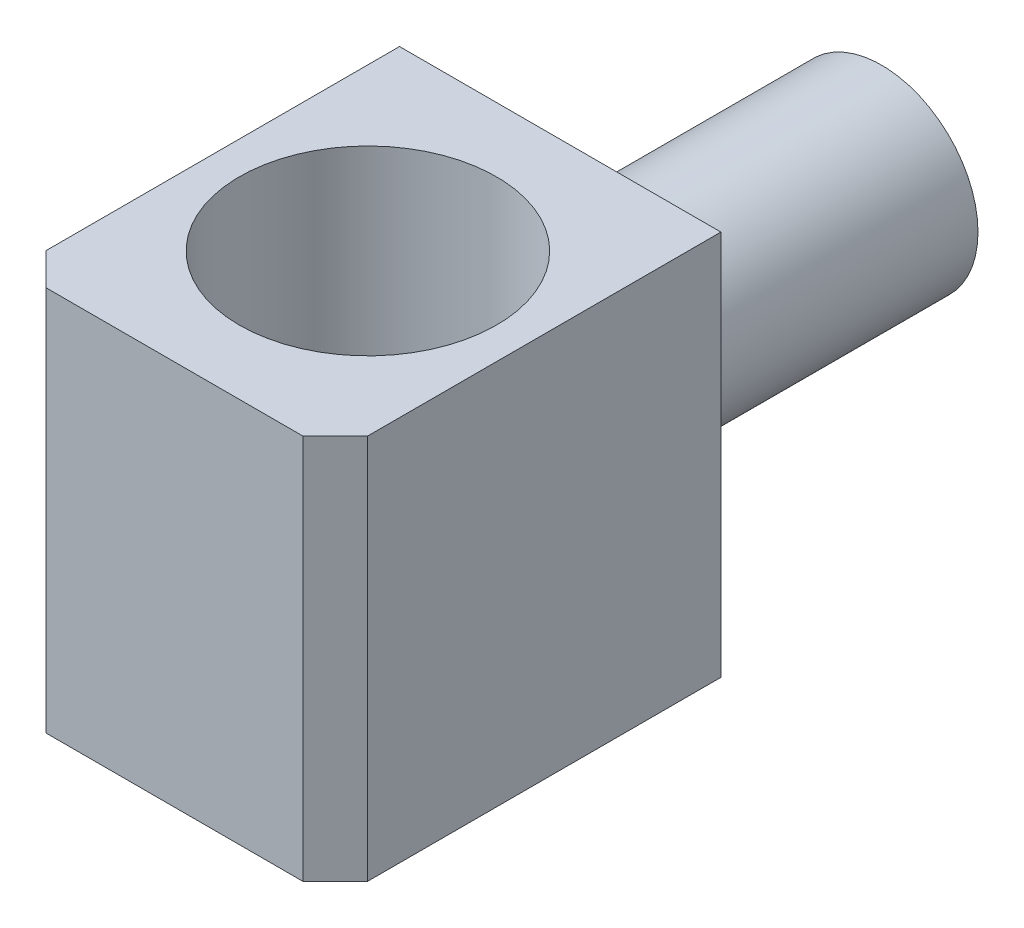
from build123d import *

# Parameters (mm, degrees)
CROQUIS1_W              = 10
CROQUIS1_H              = 12
CROQUIS1_R              = 4
SALIENTE_EXTRUIR1_DEPTH = 12
CHAFL_N1_SIZE           = 1
CROQUIS2_R              = 3
SALIENTE_EXTRUIR2_DEPTH = 10


with BuildPart() as part:
    # Croquis1 → Saliente-Extruir1 (new body)
    with BuildSketch(Plane(origin=(0, 0, 0), x_dir=(1, 0, 0), z_dir=(0, 1, 0))):
        with Locations((5, -6)):
            Rectangle(CROQUIS1_W, CROQUIS1_H)
        with Locations((5.016573561, -6)):
            Circle(CROQUIS1_R, mode=Mode.SUBTRACT)
    extrude(amount=SALIENTE_EXTRUIR1_DEPTH)

    # Chaflán1
    chafl_n1_edges = [part.edges().sort_by_distance(p)[0] for p in [
        (10, 6, 12),
        (0, 6, 12),
    ]]
    chamfer(chafl_n1_edges, length=CHAFL_N1_SIZE)

    # Croquis2 → Saliente-Extruir2 (add)
    with BuildSketch(Plane(origin=(0, 0, 0), x_dir=(-1, 0, 0), z_dir=(0, 0, -1))):
        with Locations((-5, 6)):
            Circle(CROQUIS2_R)
    extrude(amount=SALIENTE_EXTRUIR2_DEPTH)


solid = part.part
